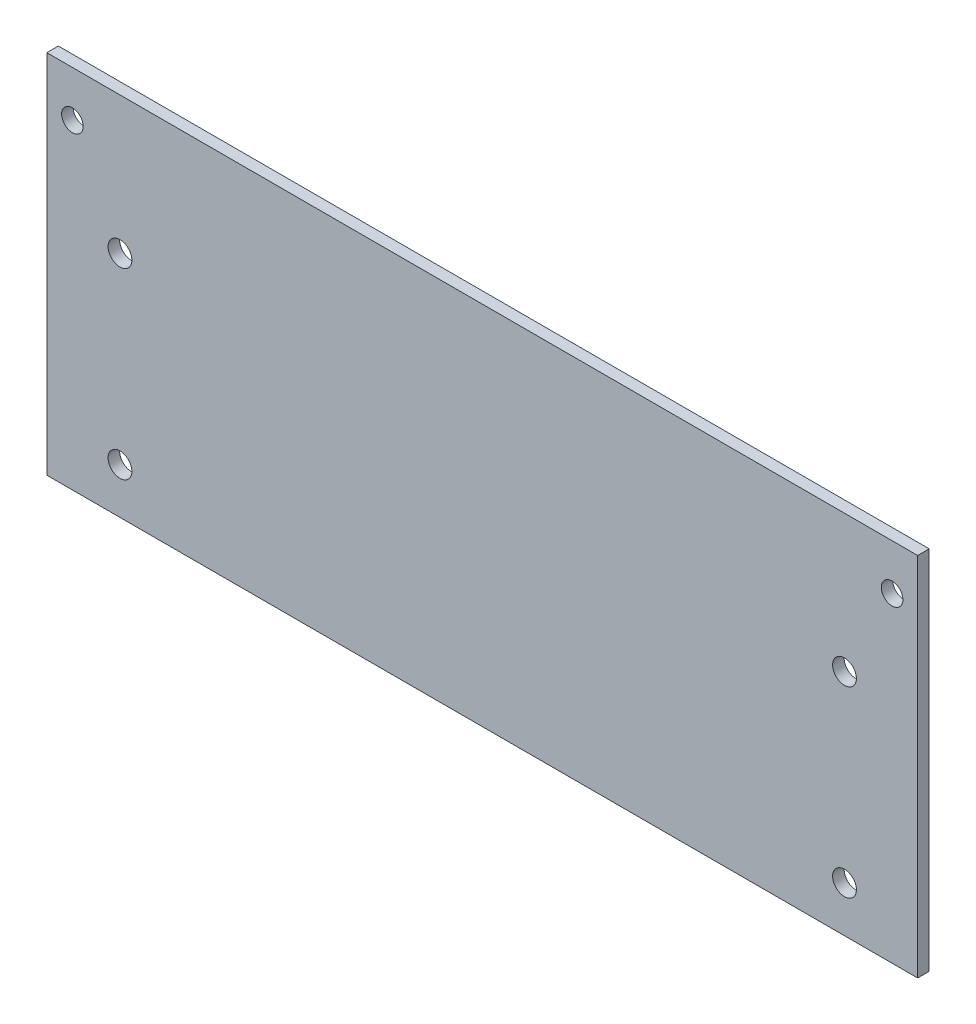
from build123d import *

# Parameters (mm, degrees)
SKETCH1_R           = 1.651
SKETCH1_R_2         = 1.4986
BOSS_EXTRUDE1_DEPTH = 1.6


with BuildPart() as part:
    # Sketch1 → Boss-Extrude1 (new body)
    with BuildSketch(Plane.XY):
        Polygon((60.452, 19.05), (60.452, 31.75), (-60.452, 31.75), (-60.452, 19.05), (-60.452, -19.05), (60.452, -19.05), align=None)
        with Locations((-50.292, 12.7)):
            Circle(SKETCH1_R, mode=Mode.SUBTRACT)
        with Locations((-50.292, -12.7)):
            Circle(SKETCH1_R, mode=Mode.SUBTRACT)
        with Locations((50.292, 12.7)):
            Circle(SKETCH1_R, mode=Mode.SUBTRACT)
        with Locations((50.292, -12.7)):
            Circle(SKETCH1_R, mode=Mode.SUBTRACT)
        with Locations((56.896, 25.4)):
            Circle(SKETCH1_R_2, mode=Mode.SUBTRACT)
        with Locations((-56.896, 25.4)):
            Circle(SKETCH1_R_2, mode=Mode.SUBTRACT)
    extrude(amount=BOSS_EXTRUDE1_DEPTH)


solid = part.part
